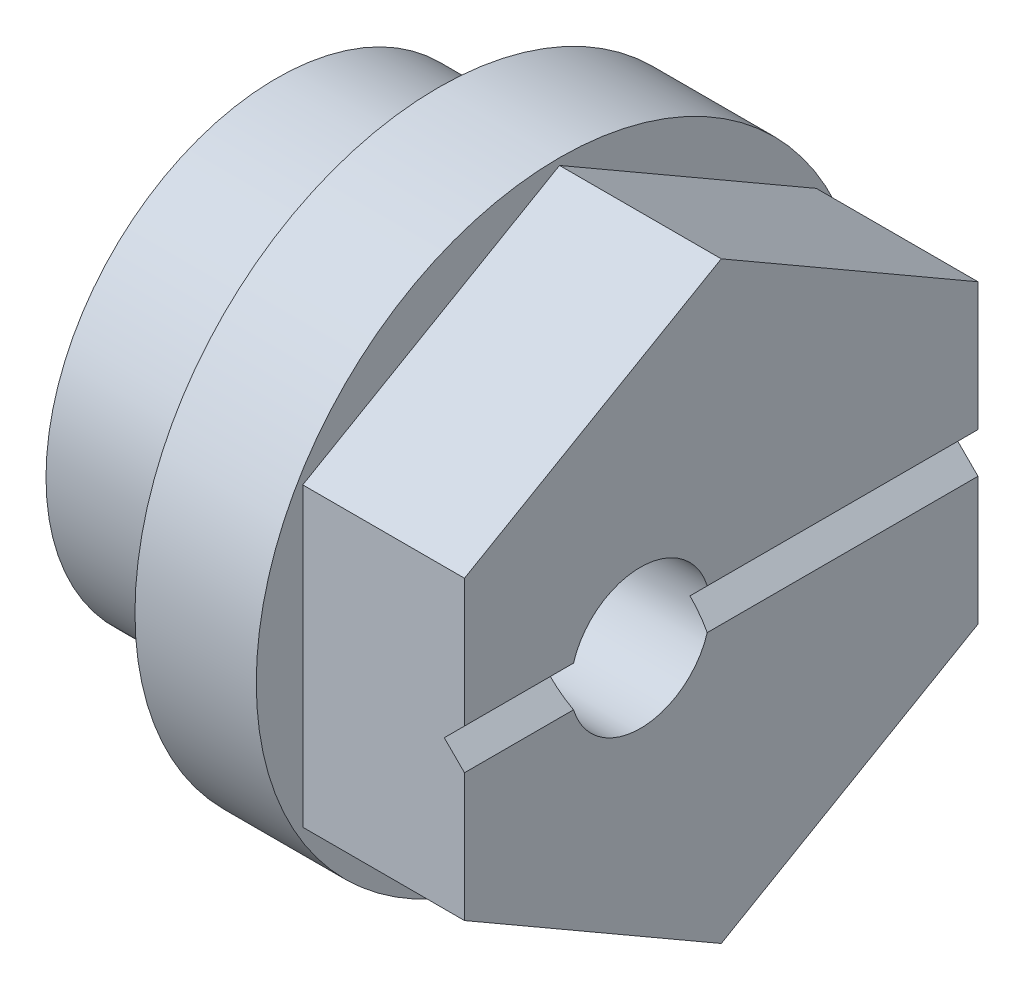
from build123d import *

# Parameters (mm, degrees)
SKETCH1_W                                      = 3
SKETCH1_H                                      = 7.5
BOSS_EXTRUDE1_DEPTH                            = 4
CUT_EXTRUDE1_DEPTH                             = 14.85
SKETCH4_R                                      = 5.7
BOSS_EXTRUDE2_DEPTH                            = 4
CBORE_FOR_5_BUTTON_HEAD_CAP_SCREW1_D           = 1.5875
CBORE_FOR_5_BUTTON_HEAD_CAP_SCREW1_CBORE_D     = 6.600000008
CBORE_FOR_5_BUTTON_HEAD_CAP_SCREW1_CBORE_DEPTH = 7.9375
F_8_32_TAPPED_HOLE1_D                          = 3.4544


with BuildPart() as part:
    # Sketch1 → Revolve1 (revolve)
    with BuildSketch(Plane.XY, mode=Mode.PRIVATE) as revolve1_sk:
        with Locations((5.5, 3.75)):
            Rectangle(SKETCH1_W, SKETCH1_H)
    revolve(revolve1_sk.sketch.rotate(Axis((4, 0, 0), (1, 0, 0)), 270), axis=Axis((4, 0, 0), (1, 0, 0)))  # turned: the seam where the file's is

    # Sketch2 → Boss-Extrude1 (add)
    with BuildSketch(Plane(origin=(7, 0, 0), x_dir=(0, 0, -1), z_dir=(1, 0, 0))):
        Polygon((0, -7.332348419), (-6.35, -3.666174209), (-6.35, 3.666174209), (0, 7.332348419), (6.35, 3.666174209), (6.35, -3.666174209), align=None)
    extrude(amount=BOSS_EXTRUDE1_DEPTH)

    # Sketch3 → Cut-Extrude1 (cut, through all)
    with BuildSketch(Plane.XY.offset(6.35)):
        Polygon((11, -0.5), (11, 0.5), (10.5, 0), align=None)
    extrude(amount=-CUT_EXTRUDE1_DEPTH, mode=Mode.SUBTRACT)

    # Sketch4 → Boss-Extrude2 (add)
    with BuildSketch(Plane.ZY.offset(-4)):
        Circle(SKETCH4_R)
    extrude(amount=BOSS_EXTRUDE2_DEPTH)

    # CBORE for #5 Button Head Cap Screw1 (through all)
    with Locations(Plane.ZY):
        with Locations((2, 0)):
            CounterBoreHole(CBORE_FOR_5_BUTTON_HEAD_CAP_SCREW1_D / 2, CBORE_FOR_5_BUTTON_HEAD_CAP_SCREW1_CBORE_D / 2, CBORE_FOR_5_BUTTON_HEAD_CAP_SCREW1_CBORE_DEPTH)

    # #8-32 Tapped Hole1 (through all)
    with Locations(Plane(origin=(11, 0, 0), x_dir=(0, 0, -1), z_dir=(1, 0, 0))):
        with Locations((-2, 0)):
            Hole(F_8_32_TAPPED_HOLE1_D / 2)


solid = part.part
